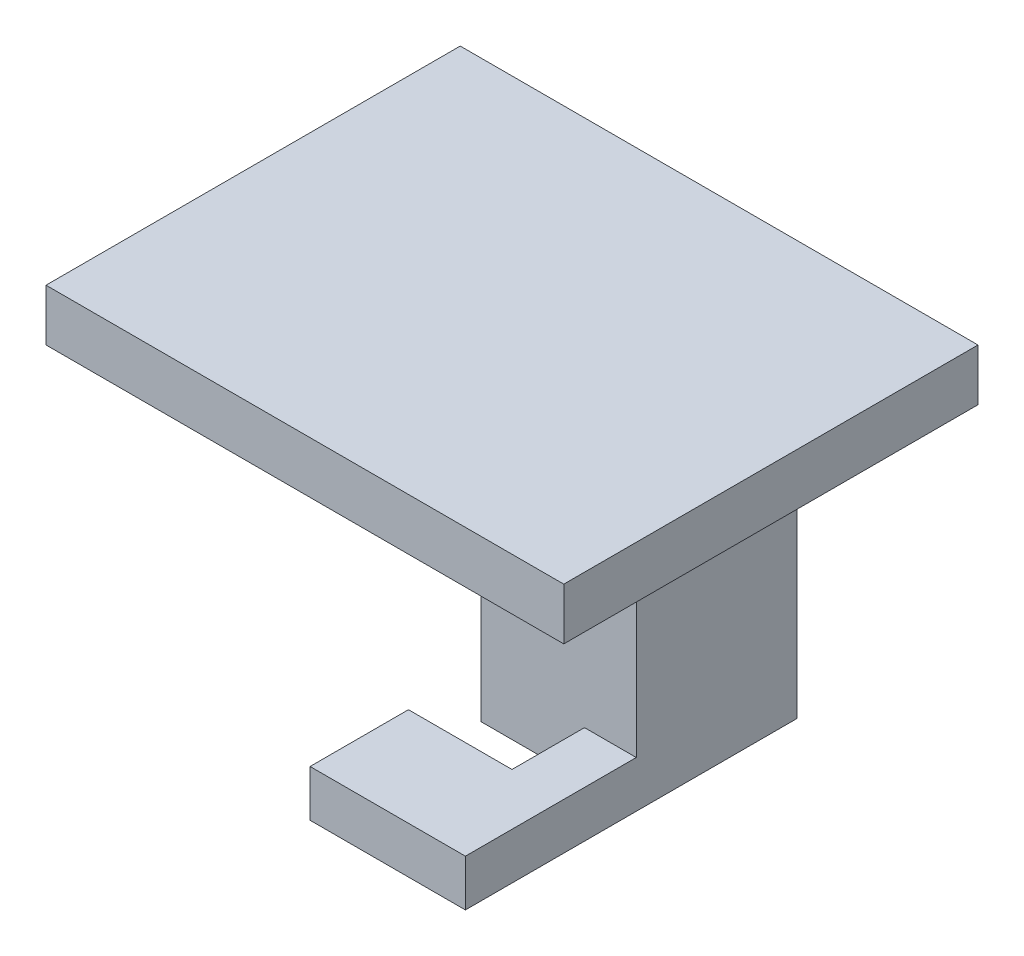
from build123d import *

# Parameters (mm, degrees)
SKETCH1_W           = 15
SKETCH1_H           = 35
BOSS_EXTRUDE1_DEPTH = 32
SKETCH4_W           = 15
SKETCH4_H           = 23
CUT_EXTRUDE2_DEPTH  = 16.5
SKETCH7_R           = 2.5
BOSS_EXTRUDE2_DEPTH = 3
SKETCH9_W           = 50
SKETCH9_H           = 40
BOSS_EXTRUDE3_DEPTH = 5
SKETCH10_W          = 7
SKETCH10_H          = 4.5
CUT_EXTRUDE3_DEPTH  = 10


with BuildPart() as part:
    # Sketch1 → Boss-Extrude1 (new body)
    with BuildSketch(Plane.XY):
        Rectangle(SKETCH1_W, SKETCH1_H)
    extrude(amount=BOSS_EXTRUDE1_DEPTH)

    # Sketch4 → Cut-Extrude2 (cut)
    with BuildSketch(Plane.XY.offset(32)):
        with Locations((0, -1.5)):
            Rectangle(SKETCH4_W, SKETCH4_H)
    extrude(amount=-CUT_EXTRUDE2_DEPTH, mode=Mode.SUBTRACT)

    # Sketch7 → Boss-Extrude2 (add)
    with BuildSketch(Plane(origin=(0, 0, 0), x_dir=(-1, 0, 0), z_dir=(0, 0, -1))):
        with Locations((0, -6.4)):
            Circle(SKETCH7_R)
    extrude(amount=BOSS_EXTRUDE2_DEPTH)

    # Sketch9 → Boss-Extrude3 (add)
    with BuildSketch(Plane(origin=(0, 17.5, 0), x_dir=(1, 0, 0), z_dir=(0, 1, 0))):
        with Locations((0, -20)):
            Rectangle(SKETCH9_W, SKETCH9_H)
    extrude(amount=BOSS_EXTRUDE3_DEPTH)

    # Sketch10 → Cut-Extrude3 (cut)
    with BuildSketch(Plane.ZY.offset(7.5)):
        with Locations((19, -15.25)):
            Rectangle(SKETCH10_W, SKETCH10_H)
    extrude(amount=-CUT_EXTRUDE3_DEPTH, mode=Mode.SUBTRACT)


solid = part.part
